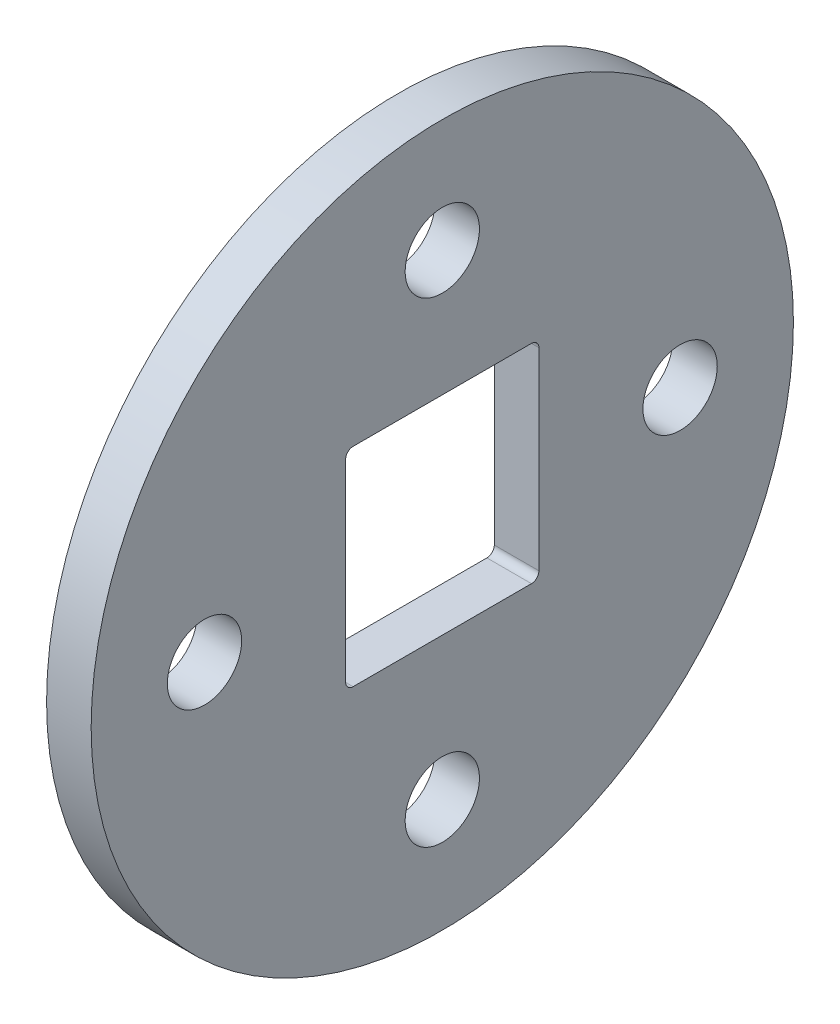
from build123d import *

# Parameters (mm, degrees)
SKETCH1_R                                           = 47.25
BOSS_EXTRUDE1_DEPTH                                 = 6
CUT_EXTRUDE1_DEPTH                                  = 20
CBORE_FOR_M5_HEX_SOCKET_HEAD_CAP_SCREW2_D           = 5.3
CBORE_FOR_M5_HEX_SOCKET_HEAD_CAP_SCREW2_DEPTH       = 20
CBORE_FOR_M5_HEX_SOCKET_HEAD_CAP_SCREW2_CBORE_D     = 10
CBORE_FOR_M5_HEX_SOCKET_HEAD_CAP_SCREW2_CBORE_DEPTH = 15.4
CBORE_FOR_M5_HEX_SOCKET_HEAD_CAP_SCREW2_TIP         = 1.59228064


with BuildPart() as part:
    # Sketch1 → Boss-Extrude1 (new body)
    with BuildSketch(Plane(origin=(0, 0, 0), x_dir=(0, 0, -1), z_dir=(1, 0, 0))):
        Circle(SKETCH1_R)
    extrude(amount=BOSS_EXTRUDE1_DEPTH)

    # Sketch2 → Cut-Extrude1 (cut)
    with BuildSketch(Plane(origin=(6, 0, 0), x_dir=(0, 0, -1), z_dir=(1, 0, 0))):
        with BuildLine():
            Line((-12, -12.85), (12, -12.85))
            ThreePointArc((12, -12.85), (12.707106781, -12.557106781), (13, -11.85))
            Line((13, -11.85), (13, 14.15))
            ThreePointArc((13, 14.15), (12.707106781, 14.857106781), (12, 15.15))
            Line((12, 15.15), (-12, 15.15))
            ThreePointArc((-12, 15.15), (-12.707106781, 14.857106781), (-13, 14.15))
            Line((-13, 14.15), (-13, -11.85))
            ThreePointArc((-13, -11.85), (-12.707106781, -12.557106781), (-12, -12.85))
        make_face()
    extrude(amount=-CUT_EXTRUDE1_DEPTH, mode=Mode.SUBTRACT)

    # CBORE for M5 Hex Socket Head Cap Screw2
    with Locations(Plane.ZY):
        with Locations((-32, 0), (0, 32), (32, 0), (0, -32)):
            CounterBoreHole(CBORE_FOR_M5_HEX_SOCKET_HEAD_CAP_SCREW2_D / 2, CBORE_FOR_M5_HEX_SOCKET_HEAD_CAP_SCREW2_CBORE_D / 2, CBORE_FOR_M5_HEX_SOCKET_HEAD_CAP_SCREW2_CBORE_DEPTH, depth=CBORE_FOR_M5_HEX_SOCKET_HEAD_CAP_SCREW2_DEPTH)
            with Locations((0, 0, -(CBORE_FOR_M5_HEX_SOCKET_HEAD_CAP_SCREW2_DEPTH + CBORE_FOR_M5_HEX_SOCKET_HEAD_CAP_SCREW2_TIP / 2))):  # 118° drill point
                Cone(0, CBORE_FOR_M5_HEX_SOCKET_HEAD_CAP_SCREW2_D / 2, CBORE_FOR_M5_HEX_SOCKET_HEAD_CAP_SCREW2_TIP, mode=Mode.SUBTRACT)


solid = part.part
